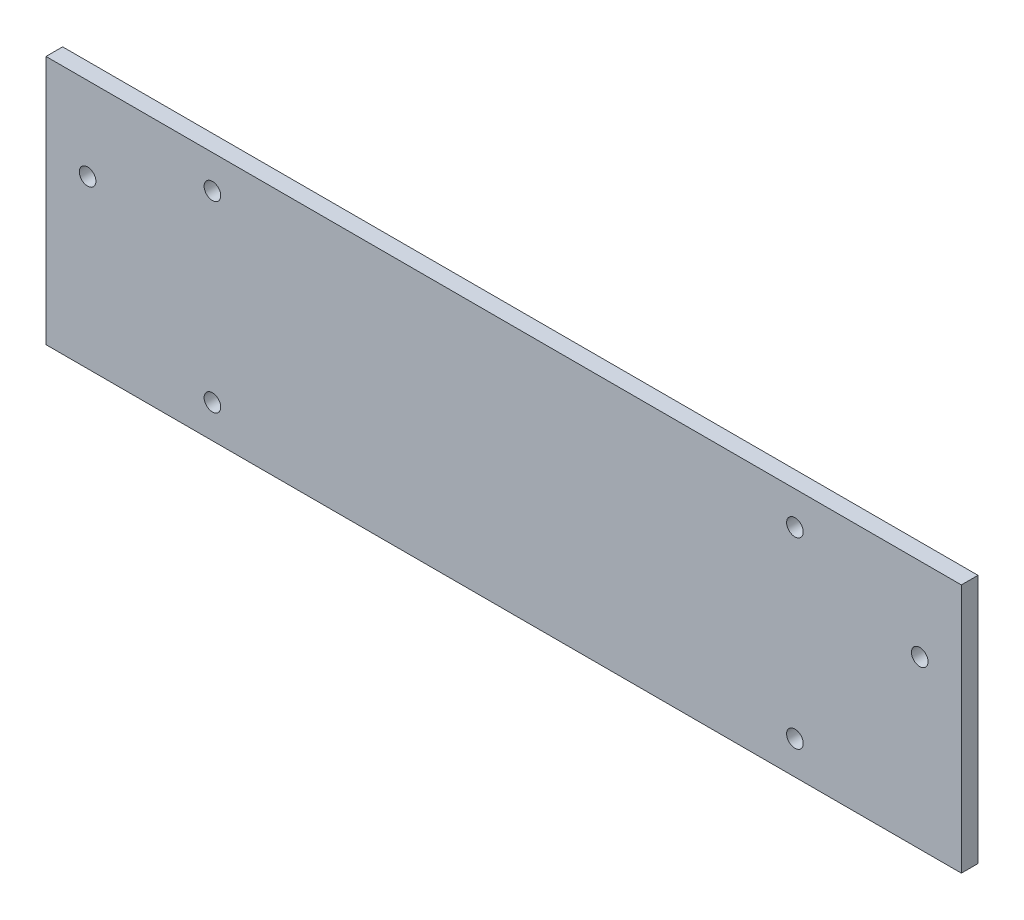
from build123d import *

# Parameters (mm, degrees)
SKETCH1_W           = 279.4
SKETCH1_H           = 76.2
BOSS_EXTRUDE1_DEPTH = 5.08
SKETCH2_R           = 2.54
CUT_EXTRUDE1_DEPTH  = 12.7


with BuildPart() as part:
    # Sketch1 → Boss-Extrude1 (new body)
    with BuildSketch(Plane.XY):
        with Locations((-27.94, -15.77124183)):
            Rectangle(SKETCH1_W, SKETCH1_H)
    extrude(amount=BOSS_EXTRUDE1_DEPTH)

    # Sketch2 → Cut-Extrude1 (cut)
    with BuildSketch(Plane.XY.offset(5.08)):
        with Locations((-154.94, -3.07124183)):
            Circle(SKETCH2_R)
        with Locations((-116.84, 12.16875817)):
            Circle(SKETCH2_R)
        with Locations((-116.84, -43.71124183)):
            Circle(SKETCH2_R)
        with Locations((60.96, -43.71124183)):
            Circle(SKETCH2_R)
        with Locations((60.96, 12.16875817)):
            Circle(SKETCH2_R)
        with Locations((99.06, -3.07124183)):
            Circle(SKETCH2_R)
    extrude(amount=-CUT_EXTRUDE1_DEPTH, mode=Mode.SUBTRACT)


solid = part.part
